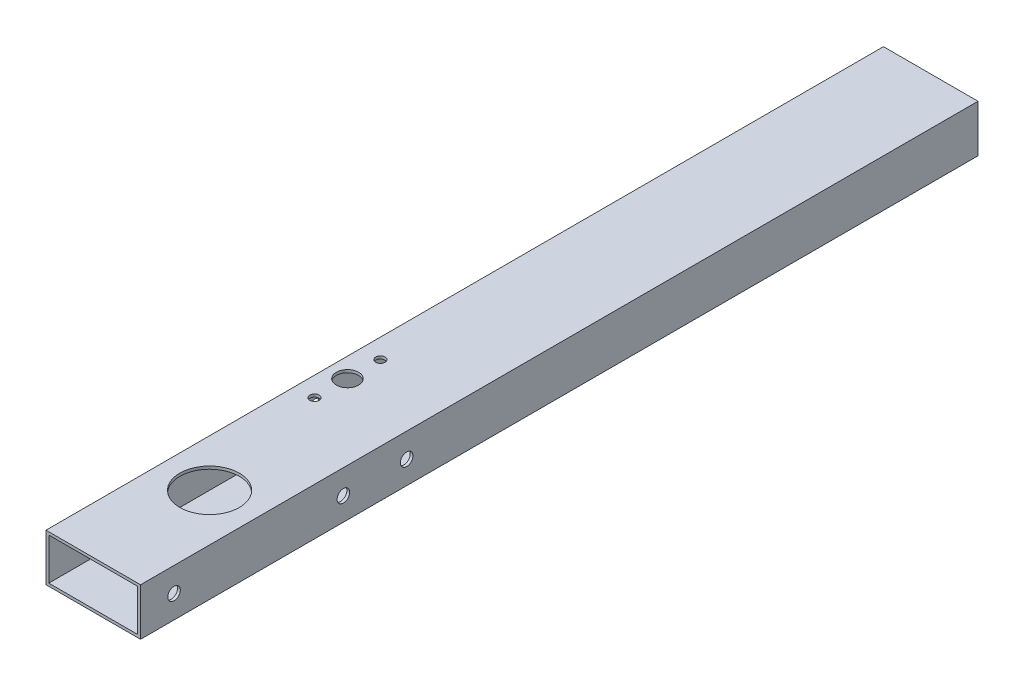
from build123d import *

# Parameters (mm, degrees)
CROQUIS1_W                    = 50.8
CROQUIS1_H                    = 25.4
CROQUIS1_W_2                  = 47.8
CROQUIS1_H_2                  = 22.4
SALIENTE_EXTRUIR1_DEPTH       = 450
CROQUIS2_R                    = 16
CORTAR_EXTRUIR1_DEPTH         = 26
TALADRO_DE_MARGEN_PARA_1_42_D = 6.7564
CROQUIS7_R                    = 6
CROQUIS7_R_2                  = 2.5
CORTAR_EXTRUIR2_DEPTH         = 25.4


with BuildPart() as part:
    # Croquis1 → Saliente-Extruir1 (new body)
    with BuildSketch(Plane.XY):
        Rectangle(CROQUIS1_W, CROQUIS1_H)
        Rectangle(CROQUIS1_W_2, CROQUIS1_H_2, mode=Mode.SUBTRACT)
    extrude(amount=SALIENTE_EXTRUIR1_DEPTH)

    # Croquis2 → Cortar-Extruir1 (cut)
    with BuildSketch(Plane(origin=(0, 12.7, 0), x_dir=(1, 0, 0), z_dir=(0, 1, 0))):
        with Locations((0, -387.5)):
            Circle(CROQUIS2_R)
    extrude(amount=-CORTAR_EXTRUIR1_DEPTH, mode=Mode.SUBTRACT)

    # Taladro de margen para 1/42 (through all)
    with Locations(Plane(origin=(-26.4, 572.488619806, 162.989101594), x_dir=(0, -1, 0), z_dir=(-1, 0, 0))):
        with Locations((572.888619806, 269.010898406), (572.888619806, 178.010898406), (572.888619806, 144.010898406)):
            Hole(TALADRO_DE_MARGEN_PARA_1_42_D / 2)

    # Croquis7 → Cortar-Extruir2 (cut)
    with BuildSketch(Plane(origin=(0, 12.7, 0), x_dir=(1, 0, 0), z_dir=(0, 1, 0))):
        with Locations((-14.9, -298.5)):
            Circle(CROQUIS7_R)
        with Locations((-14.9, -280.8)):
            Circle(CROQUIS7_R_2)
        with Locations((-14.9, -316.2)):
            Circle(CROQUIS7_R_2)
    extrude(amount=-CORTAR_EXTRUIR2_DEPTH, mode=Mode.SUBTRACT)


solid = part.part
